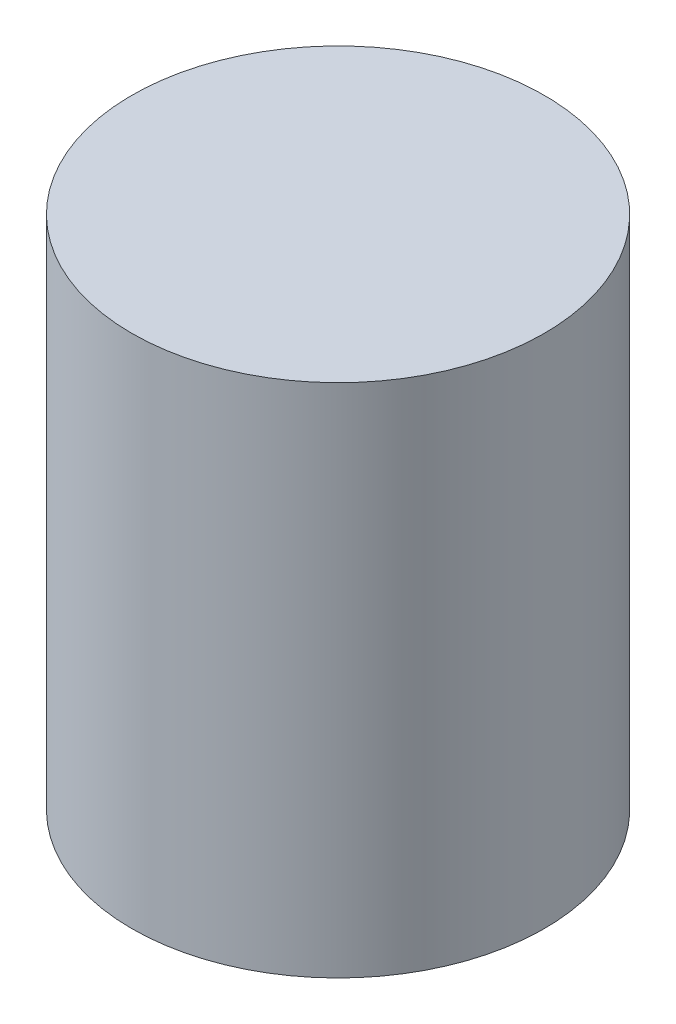
from build123d import *

# Parameters (mm, degrees)
SKETCH1_R           = 2
BOSS_EXTRUDE1_DEPTH = 5


with BuildPart() as part:
    # Sketch1 → Boss-Extrude1 (new body)
    with BuildSketch(Plane(origin=(0, 0, 0), x_dir=(1, 0, 0), z_dir=(0, 1, 0))):
        Circle(SKETCH1_R)
    extrude(amount=BOSS_EXTRUDE1_DEPTH)


solid = part.part
